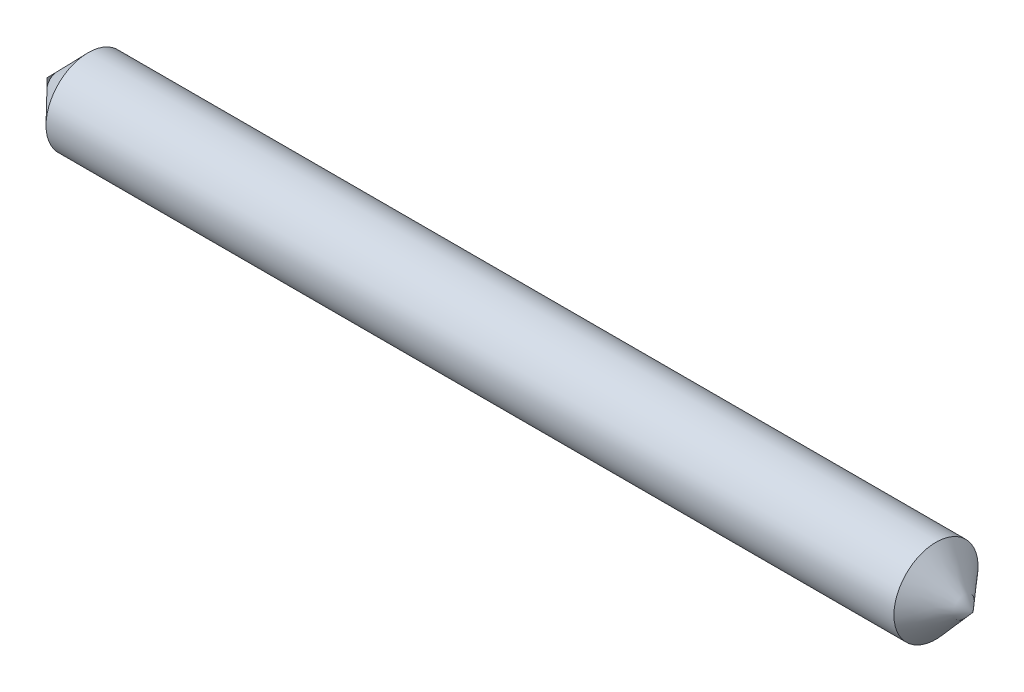
from build123d import *


with BuildPart() as part:
    # Croquis1 → Revolución2 (revolve)
    with BuildSketch(Plane.XY):
        Polygon((-79.053152984, 7.18483977), (320.946847016, 7.18483977), (304.924926316, 25.363302575), (-61.409259522, 25.363302575), align=None)
    revolve(axis=Axis((-79.053152984, 7.18483977, 0), (1, 0, 0)))


solid = part.part
